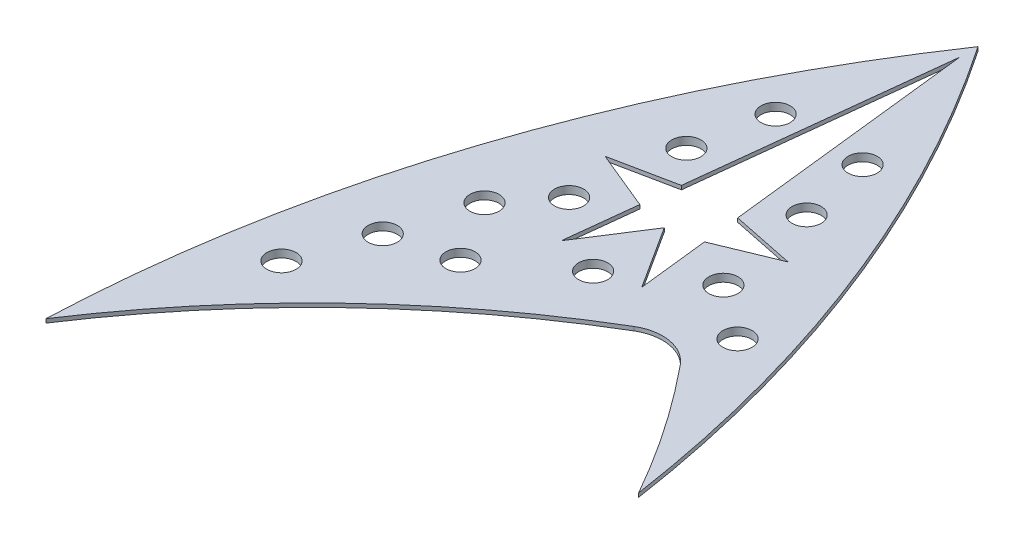
from build123d import *

# Parameters (mm, degrees)
SKETCH4_R             = 1.5
BOSS_EXTRUDE1_DEPTH   = 0.4
BOSS_EXTRUDE1_2_DEPTH = 0.4
BOSS_EXTRUDE1_3_DEPTH = 0.4
BOSS_EXTRUDE1_4_DEPTH = 0.4
SKETCH5_R             = 1.5
BOSS_EXTRUDE2_DEPTH   = 0.4


with BuildPart() as part:
    # Sketch4 → Boss-Extrude1 (new body)
    with BuildSketch(Plane(origin=(0, 0, 0), x_dir=(1, 0, 0), z_dir=(0, 1, 0))):
        with BuildLine():
            Line((36.631982775, 48.402124759), (29.724109313, 45.552485279))
            Line((29.724109313, 45.552485279), (30.536926129, 38.325609907))
            ThreePointArc((30.536926129, 38.325609907), (31.037916291, 37.567202472), (31.94599849, 37.527709405))
            ThreePointArc((31.94599849, 37.527709405), (36.434517541, 37.979126286), (40.266354995, 35.59845365))
            ThreePointArc((40.266354995, 35.59845365), (41.495664758, 34.067994846), (42.693859526, 32.513055637))
            ThreePointArc((42.693859526, 32.513055637), (40.547573161, 40.24119879), (37.949447695, 47.829379455))
            ThreePointArc((37.949447695, 47.829379455), (37.412017647, 48.394779577), (36.631982775, 48.402124759))
        make_face()
        with Locations((33.472, 43.307)):
            Circle(SKETCH4_R, mode=Mode.SUBTRACT)
        with Locations((38.989, 39.243)):
            Circle(SKETCH4_R, mode=Mode.SUBTRACT)
    extrude(amount=BOSS_EXTRUDE1_DEPTH)



with BuildPart() as body_2:
    # Sketch4 → Boss-Extrude1 2 (new body)
    with BuildSketch(Plane(origin=(0, 0, 0), x_dir=(1, 0, 0), z_dir=(0, 1, 0))):
        with BuildLine():
            Line((26.913796721, 70.539393135), (29.126057014, 50.869857351))
            Line((29.126057014, 50.869857351), (35.62874213, 49.537078309))
            ThreePointArc((35.62874213, 49.537078309), (36.597764867, 49.876549859), (36.756875392, 50.890911647))
            ThreePointArc((36.756875392, 50.890911647), (32.232858108, 60.91429454), (26.913796721, 70.539393135))
        make_face()
        with Locations((31.496, 53.848)):
            Circle(SKETCH4_R, mode=Mode.SUBTRACT)
        with Locations((29.901, 61.2)):
            Circle(SKETCH4_R, mode=Mode.SUBTRACT)
    extrude(amount=BOSS_EXTRUDE1_2_DEPTH)


with BuildPart() as body_3:
    # Sketch4 → Boss-Extrude1 3 (new body)
    with BuildSketch(Plane(origin=(0, 0, 0), x_dir=(1, 0, 0), z_dir=(0, 1, 0))):
        with BuildLine():
            Line((20.913318286, 45.552485279), (14.005444824, 48.402124759))
            ThreePointArc((14.005444824, 48.402124759), (13.225409952, 48.394779577), (12.687979904, 47.829379455))
            ThreePointArc((12.687979904, 47.829379455), (7.625203146, 31.191555875), (4.727035456, 14.043684112))
            ThreePointArc((4.727035456, 14.043684112), (15.974402208, 25.962258497), (29.061917895, 35.824946131))
            ThreePointArc((29.061917895, 35.824946131), (29.505500168, 36.453855806), (29.370974364, 37.211612641))
            Line((29.370974364, 37.211612641), (25.3187138, 43.52403979))
            Line((25.3187138, 43.52403979), (19.700923362, 34.77290143))
            Line((19.700923362, 34.77290143), (20.913318286, 45.552485279))
        make_face()
        with Locations((8.58, 22.733)):
            Circle(SKETCH4_R, mode=Mode.SUBTRACT)
        with Locations((11.374, 30.353)):
            Circle(SKETCH4_R, mode=Mode.SUBTRACT)
        with Locations((13.843, 38.354)):
            Circle(SKETCH4_R, mode=Mode.SUBTRACT)
        with Locations((17.724, 32.004)):
            Circle(SKETCH4_R, mode=Mode.SUBTRACT)
        with Locations((17.724, 43.18)):
            Circle(SKETCH4_R, mode=Mode.SUBTRACT)
        with Locations((25.527, 37.846)):
            Circle(SKETCH4_R, mode=Mode.SUBTRACT)
    extrude(amount=BOSS_EXTRUDE1_3_DEPTH)


with BuildPart() as body_4:
    # Sketch4 → Boss-Extrude1 4 (new body)
    with BuildSketch(Plane(origin=(0, 0, 0), x_dir=(1, 0, 0), z_dir=(0, 1, 0))):
        with BuildLine():
            Line((15.008685469, 49.537078309), (21.511370585, 50.869857351))
            Line((21.511370585, 50.869857351), (23.723630878, 70.539393135))
            ThreePointArc((23.723630878, 70.539393135), (18.404569491, 60.91429454), (13.880552207, 50.890911647))
            ThreePointArc((13.880552207, 50.890911647), (14.039662732, 49.876549859), (15.008685469, 49.537078309))
        make_face()
        with Locations((19.375, 53.594)):
            Circle(SKETCH4_R, mode=Mode.SUBTRACT)
        with Locations((20.925, 61.225)):
            Circle(SKETCH4_R, mode=Mode.SUBTRACT)
    extrude(amount=BOSS_EXTRUDE1_4_DEPTH)


with BuildPart() as part_1:
    add(part.part)

    add(body_2.part)  # Boss-Extrude2 merges body 2

    add(body_3.part)  # Boss-Extrude2 merges body 3

    add(body_4.part)  # Boss-Extrude2 merges body 4
    # Sketch5 → Boss-Extrude2 (add)
    with BuildSketch(Plane(origin=(0, 0.4, 0), x_dir=(1, 0, 0), z_dir=(0, 1, 0))):
        with BuildLine():
            ThreePointArc((25.3187138, 77.655988793), (8.417285199, 43.223132296), (1.60825988, 5.475058578))
            ThreePointArc((1.60825988, 5.475058578), (15.395050063, 22.022293224), (32.560079542, 35.031840527))
            ThreePointArc((32.560079542, 35.031840527), (35.635218263, 35.591596594), (38.333143822, 34.01330553))
            ThreePointArc((38.333143822, 34.01330553), (43.27239761, 27.425793547), (47.621637666, 20.434681115))
            ThreePointArc((47.621637666, 20.434681115), (39.681799875, 50.297117055), (25.3187138, 77.655988793))
        make_face()
        with Locations((8.58, 22.733)):
            Circle(SKETCH5_R, mode=Mode.SUBTRACT)
        with Locations((11.374, 30.353)):
            Circle(SKETCH5_R, mode=Mode.SUBTRACT)
        with Locations((17.724, 43.18)):
            Circle(SKETCH5_R, mode=Mode.SUBTRACT)
        with Locations((13.843, 38.354)):
            Circle(SKETCH5_R, mode=Mode.SUBTRACT)
        with Locations((17.724, 32.004)):
            Circle(SKETCH5_R, mode=Mode.SUBTRACT)
        with Locations((38.989, 39.243)):
            Circle(SKETCH5_R, mode=Mode.SUBTRACT)
        with Locations((33.472, 43.307)):
            Circle(SKETCH5_R, mode=Mode.SUBTRACT)
        with Locations((31.496, 53.848)):
            Circle(SKETCH5_R, mode=Mode.SUBTRACT)
        with Locations((29.901, 61.2)):
            Circle(SKETCH5_R, mode=Mode.SUBTRACT)
        with Locations((20.925, 61.225)):
            Circle(SKETCH5_R, mode=Mode.SUBTRACT)
        with Locations((19.375, 53.594)):
            Circle(SKETCH5_R, mode=Mode.SUBTRACT)
        with Locations((25.527, 37.846)):
            Circle(SKETCH5_R, mode=Mode.SUBTRACT)
        Polygon((22.423901789, 50.036100284), (25.3187138, 75.774305051), (28.21352581, 50.036100284), (34.731994844, 48.700086198), (28.646152557, 46.189551437), (29.464018945, 38.917779558), (25.3187138, 45.375147323), (21.173408654, 38.917779558), (21.991275042, 46.189551437), (15.905432755, 48.700086198), align=None, mode=Mode.SUBTRACT)
    extrude(amount=BOSS_EXTRUDE2_DEPTH)


solid = part_1.part
